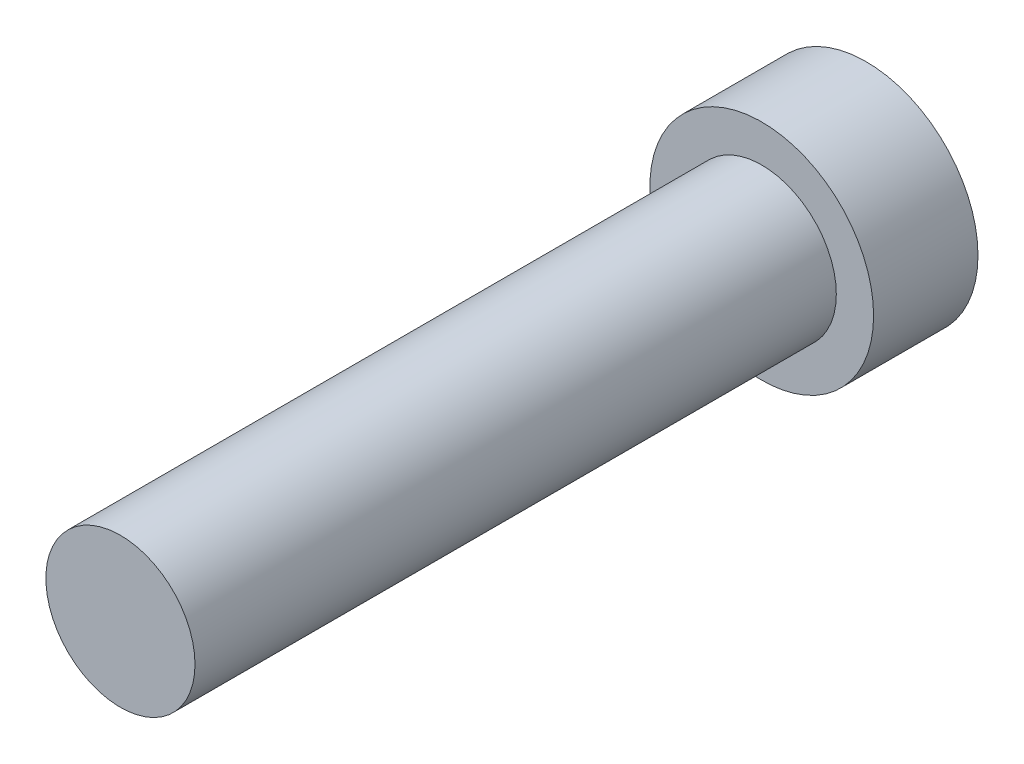
from build123d import *

# Parameters (mm, degrees)
SKETCH1_R           = 7.5
BOSS_EXTRUDE1_DEPTH = 7
SKETCH2_R           = 5
BOSS_EXTRUDE2_DEPTH = 43


with BuildPart() as part:
    # Sketch1 → Boss-Extrude1 (new body)
    with BuildSketch(Plane.XY):
        Circle(SKETCH1_R)
    extrude(amount=BOSS_EXTRUDE1_DEPTH)

    # Sketch2 → Boss-Extrude2 (add)
    with BuildSketch(Plane.XY.offset(7)):
        Circle(SKETCH2_R)
    extrude(amount=BOSS_EXTRUDE2_DEPTH)


solid = part.part
